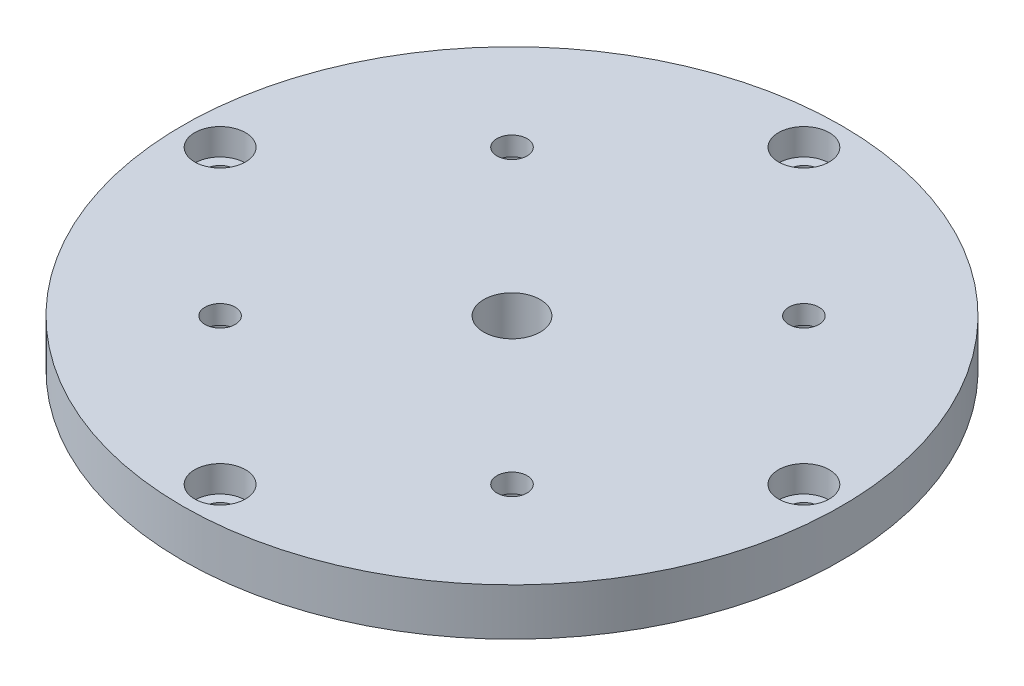
from build123d import *

# Parameters (mm, degrees)
SKETCH1_R           = 35
SKETCH1_R_2         = 3
BOSS_EXTRUDE1_DEPTH = 5
SKETCH2_R           = 1.6
CUT_EXTRUDE1_DEPTH  = 5
SKETCH4_R           = 2.8
SKETCH4_R_2         = 1.6
CUT_EXTRUDE2_DEPTH  = 3
SKETCH5_R           = 1.6
CUT_EXTRUDE3_DEPTH  = 10
SKETCH6_R           = 2.7
CUT_EXTRUDE4_DEPTH  = 2.8


with BuildPart() as part:
    # Sketch1 → Boss-Extrude1 (new body)
    with BuildSketch(Plane(origin=(0, 0, 0), x_dir=(1, 0, 0), z_dir=(0, 1, 0))):
        Circle(SKETCH1_R)
        Circle(SKETCH1_R_2, mode=Mode.SUBTRACT)
    extrude(amount=BOSS_EXTRUDE1_DEPTH)

    # Sketch2 → Cut-Extrude1 (cut)
    with BuildSketch(Plane.XZ):
        with Locations((15.5, 15.5)):
            Circle(SKETCH2_R)
        with Locations((15.5, -15.5)):
            Circle(SKETCH2_R)
        with Locations((-15.5, -15.5)):
            Circle(SKETCH2_R)
        with Locations((-15.5, 15.5)):
            Circle(SKETCH2_R)
    extrude(amount=-CUT_EXTRUDE1_DEPTH, mode=Mode.SUBTRACT)

    # Sketch4 → Cut-Extrude2 (cut)
    with BuildSketch(Plane.XZ):
        with Locations((-15.5, 15.5)):
            Circle(SKETCH4_R)
        with Locations((-15.5, 15.5)):
            Circle(SKETCH4_R_2, mode=Mode.SUBTRACT)
        with Locations((15.5, 15.5)):
            Circle(SKETCH4_R)
        with Locations((15.5, 15.5)):
            Circle(SKETCH4_R_2, mode=Mode.SUBTRACT)
        with Locations((15.5, -15.5)):
            Circle(SKETCH4_R)
        with Locations((15.5, -15.5)):
            Circle(SKETCH4_R_2, mode=Mode.SUBTRACT)
        with Locations((-15.5, -15.5)):
            Circle(SKETCH4_R)
        with Locations((-15.5, -15.5)):
            Circle(SKETCH4_R_2, mode=Mode.SUBTRACT)
    extrude(amount=-CUT_EXTRUDE2_DEPTH, mode=Mode.SUBTRACT)

    # Sketch5 → Cut-Extrude3 (cut)
    with BuildSketch(Plane(origin=(0, 5, 0), x_dir=(1, 0, 0), z_dir=(0, 1, 0))):
        with Locations((0, 31)):
            Circle(SKETCH5_R)
        with Locations((31, 0)):
            Circle(SKETCH5_R)
        with Locations((0, -31)):
            Circle(SKETCH5_R)
        with Locations((-31, 0)):
            Circle(SKETCH5_R)
    extrude(amount=-CUT_EXTRUDE3_DEPTH, mode=Mode.SUBTRACT)

    # Sketch6 → Cut-Extrude4 (cut)
    with BuildSketch(Plane(origin=(0, 5, 0), x_dir=(1, 0, 0), z_dir=(0, 1, 0))):
        with Locations((0, 31)):
            Circle(SKETCH6_R)
        with Locations((31, 0)):
            Circle(SKETCH6_R)
        with Locations((0, -31)):
            Circle(SKETCH6_R)
        with Locations((-31, 0)):
            Circle(SKETCH6_R)
    extrude(amount=-CUT_EXTRUDE4_DEPTH, mode=Mode.SUBTRACT)


solid = part.part
